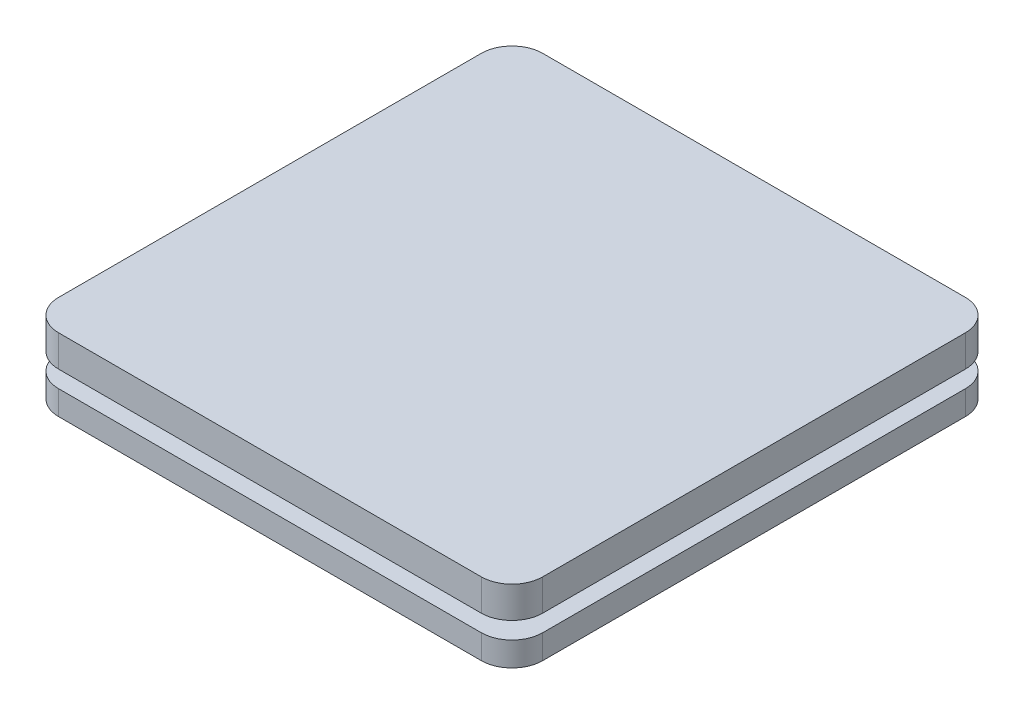
from build123d import *

# Parameters (mm, degrees)
SKETCH1_W                                   = 100
SKETCH1_H                                   = 100
BOSS_EXTRUDE1_DEPTH                         = 6.5
SKETCH2_W                                   = 100
SKETCH2_H                                   = 100
BOSS_EXTRUDE2_DEPTH                         = 5
SKETCH3_W                                   = 100
SKETCH3_H                                   = 100
BOSS_EXTRUDE3_DEPTH                         = 5
CUT_EXTRUDE1_DEPTH                          = 101
SKETCH6_W                                   = 100
SKETCH6_H                                   = 100
SKETCH6_W_2                                 = 90
SKETCH6_H_2                                 = 90
CUT_EXTRUDE2_DEPTH                          = 5
SKETCH9_W                                   = 70
SKETCH9_H                                   = 70
BOSS_EXTRUDE4_DEPTH                         = 3.5
CBORE_FOR_M5_CHEESE_HEAD_SCREW1_D           = 3.332
CBORE_FOR_M5_CHEESE_HEAD_SCREW1_DEPTH       = 11
CBORE_FOR_M5_CHEESE_HEAD_SCREW1_CBORE_D     = 8
CBORE_FOR_M5_CHEESE_HEAD_SCREW1_CBORE_DEPTH = 5
CBORE_FOR_M5_CHEESE_HEAD_SCREW1_TIP         = 1.001033791
FILLET1_R                                   = 6.35
CHAMFER1_SIZE                               = 6.35
SKETCH14_W                                  = 25
SKETCH14_H                                  = 50
CUT_EXTRUDE3_DEPTH                          = 5


with BuildPart() as part:
    # Sketch1 → Boss-Extrude1 (new body)
    with BuildSketch(Plane(origin=(0, 0, 0), x_dir=(1, 0, 0), z_dir=(0, 1, 0))):
        Rectangle(SKETCH1_W, SKETCH1_H)
    extrude(amount=BOSS_EXTRUDE1_DEPTH)



with BuildPart() as body_2:
    # Sketch2 → Boss-Extrude2 (new body)
    with BuildSketch(Plane(origin=(0, -3.5, 0), x_dir=(-1, 0, 0), z_dir=(0, -1, 0))):
        Rectangle(SKETCH2_W, SKETCH2_H)
    extrude(amount=BOSS_EXTRUDE2_DEPTH)

    # Sketch3 → Boss-Extrude3 (add)
    with BuildSketch(Plane.XZ.offset(8.5)):
        Rectangle(SKETCH3_W, SKETCH3_H)
    extrude(amount=BOSS_EXTRUDE3_DEPTH)

    # Sketch4 → Cut-Extrude1 (cut, through all)
    with BuildSketch(Plane.XY.offset(50)):
        Polygon((-25, -13.5), (-25, -8.5), (-5, -8.5), (-7.886751346, -13.5), align=None)
    cut_extrude1 = extrude(amount=-CUT_EXTRUDE1_DEPTH, mode=Mode.SUBTRACT)

    # Mirror1: Cut-Extrude1 across plane
    add(cut_extrude1.mirror(Plane(origin=(0, 0, 0), x_dir=(0, 0, 1), z_dir=(1, 0, 0))), mode=Mode.SUBTRACT)

    # Sketch6 → Cut-Extrude2 (cut)
    with BuildSketch(Plane.XZ.offset(13.5)):
        Rectangle(SKETCH6_W, SKETCH6_H)
        Rectangle(SKETCH6_W_2, SKETCH6_H_2, mode=Mode.SUBTRACT)
    extrude(amount=-CUT_EXTRUDE2_DEPTH, mode=Mode.SUBTRACT)


with BuildPart() as part_1:
    add(part.part)

    add(body_2.part)  # Boss-Extrude4 merges body 2
    # Sketch9 → Boss-Extrude4 (add)
    with BuildSketch(Plane.XZ):
        Rectangle(SKETCH9_W, SKETCH9_H)
    extrude(amount=BOSS_EXTRUDE4_DEPTH)

    # CBORE for M5 Cheese Head Screw1
    with Locations(Plane(origin=(0, -13.5, 0), x_dir=(-1, 0, 0), z_dir=(0, -1, 0))):
        with Locations((-32, 32), (0, 32), (32, 32), (32, -32), (0, -32), (-32, -32)):
            CounterBoreHole(CBORE_FOR_M5_CHEESE_HEAD_SCREW1_D / 2, CBORE_FOR_M5_CHEESE_HEAD_SCREW1_CBORE_D / 2, CBORE_FOR_M5_CHEESE_HEAD_SCREW1_CBORE_DEPTH, depth=CBORE_FOR_M5_CHEESE_HEAD_SCREW1_DEPTH)
            with Locations((0, 0, -(CBORE_FOR_M5_CHEESE_HEAD_SCREW1_DEPTH + CBORE_FOR_M5_CHEESE_HEAD_SCREW1_TIP / 2))):  # 118° drill point
                Cone(0, CBORE_FOR_M5_CHEESE_HEAD_SCREW1_D / 2, CBORE_FOR_M5_CHEESE_HEAD_SCREW1_TIP, mode=Mode.SUBTRACT)

    # Fillet1
    fillet1_edges = [part_1.edges().sort_by_distance(p)[0] for p in [
        (50, -6, 50),
        (-50, -6, -50),
        (-50, -6, 50),
        (50, -6, -50),
        (-50, 3.25, -50),
        (50, 3.25, -50),
        (50, 3.25, 50),
        (-50, 3.25, 50),
    ]]
    fillet(fillet1_edges, radius=FILLET1_R)

    # Chamfer1
    chamfer1_edges = [part_1.edges().sort_by_distance(p)[0] for p in [
        (45, -11, -45),
        (45, -11, 45),
        (-45, -11, 45),
        (-45, -11, -45),
    ]]
    chamfer(chamfer1_edges, length=CHAMFER1_SIZE)

    # Sketch14 → Cut-Extrude3 (cut)
    with BuildSketch(Plane.XZ.offset(13.5)):
        with Locations((-37.5, 0)):
            Rectangle(SKETCH14_W, SKETCH14_H)
    cut_extrude3 = extrude(amount=-CUT_EXTRUDE3_DEPTH, mode=Mode.SUBTRACT)

    # Mirror2: Cut-Extrude3 across plane
    add(cut_extrude3.mirror(Plane(origin=(0, 0, 0), x_dir=(0, 0, 1), z_dir=(1, 0, 0))), mode=Mode.SUBTRACT)


solid = part_1.part
